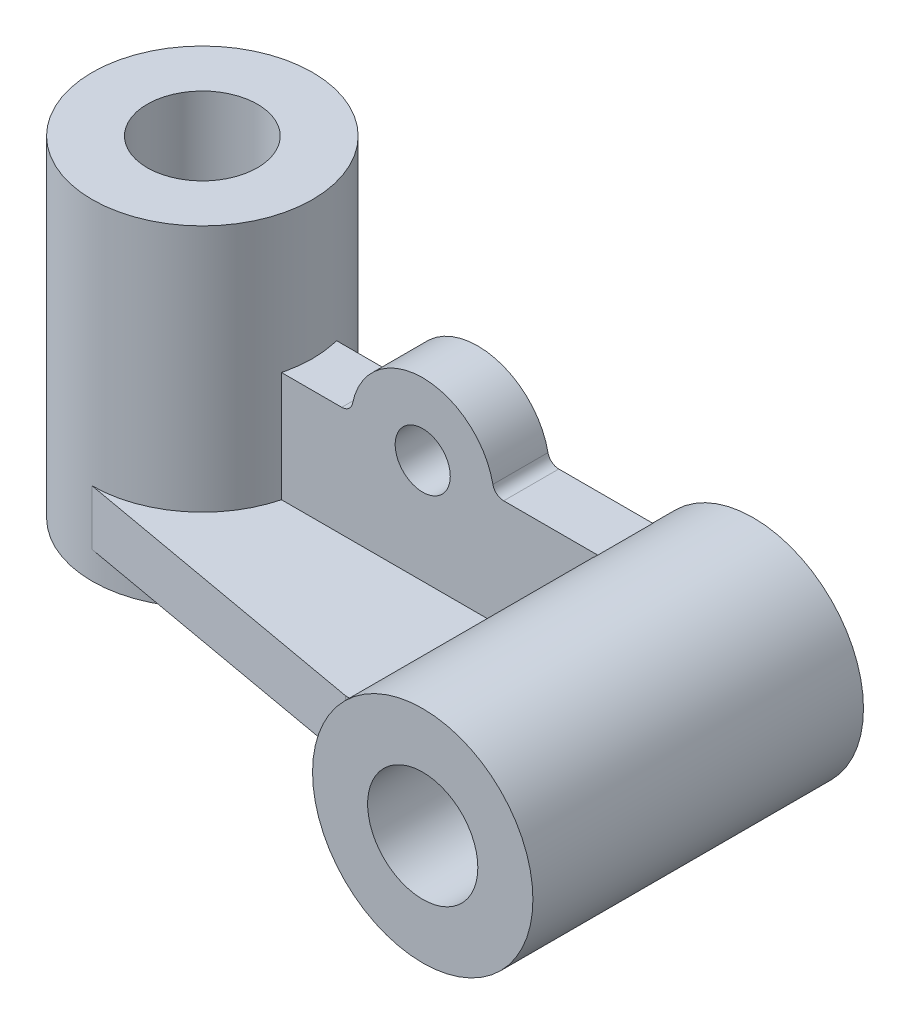
from build123d import *

# Parameters (mm, degrees)
SKETCH1_W          = 20
SKETCH1_H          = 60
SKETCH2_R          = 10
CUT_EXTRUDE1_DEPTH = 61
SKETCH3_R          = 20
SKETCH3_R_2        = 10
CYL_BLUE_DEPTH     = 60
SKETCH4_R          = 5
BASE_YELLOW_DEPTH  = 10
BASE_RED_DEPTH     = 10


with BuildPart() as part:
    # Sketch1 → cyl-purple (revolve)
    with BuildSketch(Plane.XY):
        with Locations((10, 0)):
            Rectangle(SKETCH1_W, SKETCH1_H)
    revolve(axis=Axis((0, 30, 0), (0, -1, 0)))

    # Sketch2 → Cut-Extrude1 (cut, through all)
    with BuildSketch(Plane(origin=(0, 30, 0), x_dir=(1, 0, 0), z_dir=(0, 1, 0))):
        Circle(SKETCH2_R)
    extrude(amount=-CUT_EXTRUDE1_DEPTH, mode=Mode.SUBTRACT)


with BuildPart() as body_2:
    # Sketch3 → cyl-blue (new body)
    with BuildSketch(Plane.XY.offset(50)):
        with Locations((90, -10)):
            Circle(SKETCH3_R)
        with Locations((90, -10)):
            Circle(SKETCH3_R_2, mode=Mode.SUBTRACT)
    extrude(amount=-CYL_BLUE_DEPTH)


with BuildPart() as body_3:
    # Sketch4 → base-yellow (new body)
    with BuildSketch(Plane.XY.offset(-5)):
        with BuildLine():
            Line((10, -15), (70.635083269, -15))
            ThreePointArc((70.635083269, -15), (70.879673523, -4.133730706), (76.771243445, 5))
            Line((76.771243445, 5), (59.696938457, 5))
            ThreePointArc((59.696938457, 5), (58.432027393, 5.450806662), (57.737346662, 6.6))
            ThreePointArc((57.737346662, 6.6), (45, 17), (32.262653338, 6.6))
            ThreePointArc((32.262653338, 6.6), (31.567972607, 5.450806662), (30.303061543, 5))
            Line((30.303061543, 5), (10, 5))
            Line((10, 5), (10, -15))
        make_face()
        with Locations((45, 4)):
            Circle(SKETCH4_R, mode=Mode.SUBTRACT)
    extrude(amount=BASE_YELLOW_DEPTH)


with BuildPart() as body_4:
    # Sketch6 → base-red (new body)
    with BuildSketch(Plane(origin=(0, -25, 0), x_dir=(1, 0, 0), z_dir=(0, 1, 0))):
        with BuildLine():
            Line((0, -20), (56, -30))
            Line((56, -30), (77.309100809, -30))
            Line((77.309100809, -30), (77.309100809, -5))
            Line((77.309100809, -5), (19.364916731, -5))
            ThreePointArc((19.364916731, -5), (12.247448714, -15.811388301), (0, -20))
        make_face()
    extrude(amount=BASE_RED_DEPTH)


solid = Compound([part.part, body_2.part, body_3.part, body_4.part])
